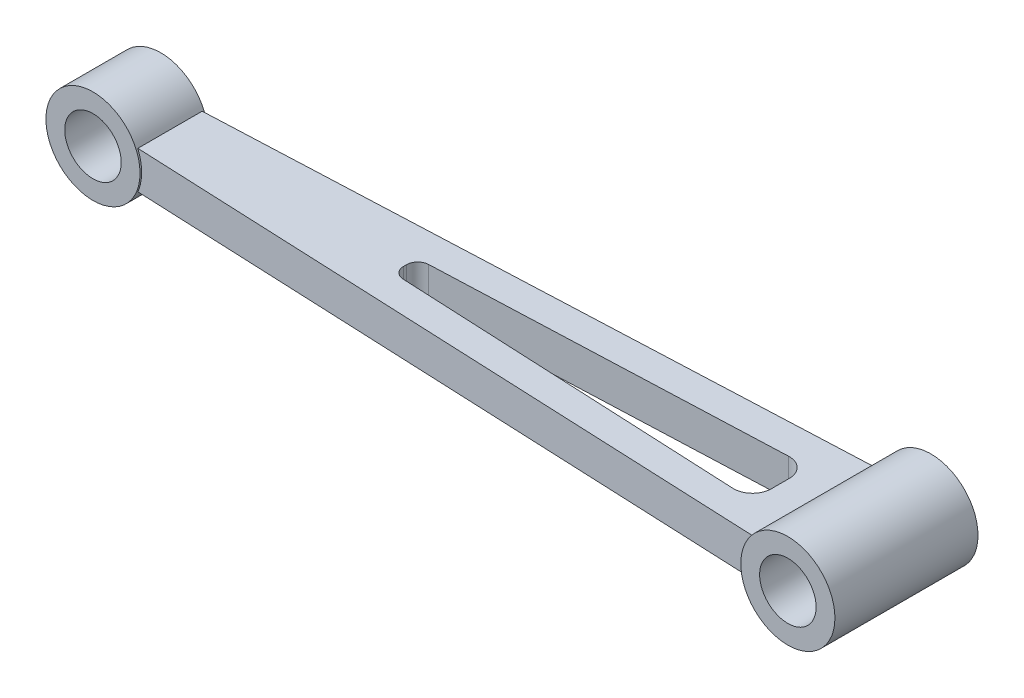
from build123d import *

# Parameters (mm, degrees)
SKETCH1_R           = 7.5
BOSS_EXTRUDE1_DEPTH = 9
SKETCH2_R           = 7.5
BOSS_EXTRUDE2_DEPTH = 19
BOSS_EXTRUDE3_DEPTH = 5
SKETCH4_R           = 12.5
BOSS_EXTRUDE4_DEPTH = 9
SKETCH6_R           = 12.5
BOSS_EXTRUDE5_DEPTH = 19
SKETCH7_R           = 7.5
CUT_EXTRUDE1_DEPTH  = 19
CUT_EXTRUDE2_DEPTH  = 19


with BuildPart() as part:
    # Sketch1 → Boss-Extrude1 (new body, symmetric)
    with BuildSketch(Plane.XY):
        Circle(SKETCH1_R)
    extrude(amount=BOSS_EXTRUDE1_DEPTH, both=True)



with BuildPart() as body_2:
    # Sketch2 → Boss-Extrude2 (new body, symmetric)
    with BuildSketch(Plane.XY):
        with Locations((194.56, 0)):
            Circle(SKETCH2_R)
    extrude(amount=BOSS_EXTRUDE2_DEPTH, both=True)


with BuildPart() as body_3:
    # Sketch3 → Boss-Extrude3 (new body, symmetric)
    with BuildSketch(Plane(origin=(0, 0, 0), x_dir=(1, 0, 0), z_dir=(0, 1, 0))):
        Polygon((7.5, 8.362970839), (187.06, 16.2), (187.06, -16.20477539), (7.5, -8.362286729), align=None)
    extrude(amount=BOSS_EXTRUDE3_DEPTH, both=True)


with BuildPart() as part_1:
    add(part.part)

    add(body_3.part)  # Boss-Extrude4 merges body 3
    # Sketch4 → Boss-Extrude4 (add, symmetric)
    with BuildSketch(Plane.XY):
        Circle(SKETCH4_R)
    extrude(amount=BOSS_EXTRUDE4_DEPTH, both=True)


    add(body_2.part)  # Boss-Extrude5 merges body 2
    # Sketch6 → Boss-Extrude5 (add, symmetric)
    with BuildSketch(Plane.XY):
        with Locations((194.56, 0)):
            Circle(SKETCH6_R)
    extrude(amount=BOSS_EXTRUDE5_DEPTH, both=True)

    # Sketch7 → Cut-Extrude1 (cut, symmetric)
    with BuildSketch(Plane.XY):
        Circle(SKETCH7_R)
        with Locations((194.56, 0)):
            Circle(SKETCH7_R)
    extrude(amount=CUT_EXTRUDE1_DEPTH, both=True, mode=Mode.SUBTRACT)

    # Sketch8 → Cut-Extrude2 (cut, symmetric)
    with BuildSketch(Plane(origin=(0, 5, 0), x_dir=(1, 0, 0), z_dir=(0, 1, 0))):
        with BuildLine():
            Line((76.769384169, 3.36885549), (168.688973616, 7.067498603))
            ThreePointArc((168.688973616, 7.067498603), (172.353731231, 5.677448491), (173.89, 2.071541398))
            Line((173.89, 2.071541398), (173.89, -2.721863896))
            ThreePointArc((173.89, -2.721863896), (172.341389234, -6.33958588), (168.654835057, -7.716330579))
            Line((168.654835057, -7.716330579), (76.748901034, -3.388930862))
            ThreePointArc((76.748901034, -3.388930862), (74.719366809, -2.463084392), (73.89, -0.392250852))
            Line((73.89, -0.392250852), (73.89, 0.371281167))
            ThreePointArc((73.89, 0.371281167), (74.726455744, 2.449519905), (76.769384169, 3.36885549))
        make_face()
    extrude(amount=CUT_EXTRUDE2_DEPTH, both=True, mode=Mode.SUBTRACT)


solid = part_1.part
